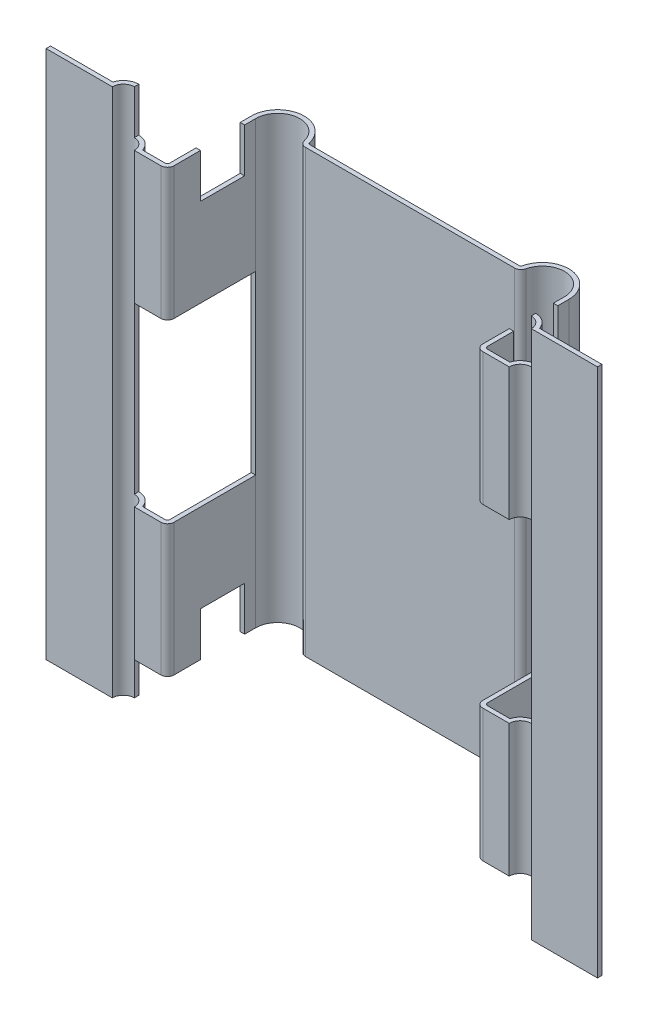
from build123d import *

# Parameters (mm, degrees)
EXTRUDE_THIN1_DEPTH      = 6
EXTRUDE_THIN1_DEPTH_BACK = 6
SKETCH2_W                = 2
SKETCH2_H                = 4
SKETCH2_W_2              = 3
SKETCH2_H_2              = 1
EXTRUDE1_DEPTH           = 4.5
EXTRUDE1_DEPTH_BACK      = 4.5
SKETCH3_W                = 1
SKETCH3_H                = 1
EXTRUDE2_DEPTH           = 10
EXTRUDE2_DEPTH_BACK      = 10


with BuildPart() as part:
    # Sketch1 → Extrude-Thin1 (new body, two sides)
    with BuildSketch(Plane(origin=(0, 0, 0), x_dir=(1, 0, 0), z_dir=(0, 1, 0))) as extrude_thin1_sk:
        with BuildLine():
            Line((-6.25, 0), (-4.75, 0))
            ThreePointArc((-4.75, 0), (-4.5, 0.25), (-4.25, 0))
            Line((-4.25, 0), (-3.65, 0))
            ThreePointArc((-3.65, 0), (-3.543933983, 0.043933983), (-3.5, 0.15))
            Line((-3.5, 0.15), (-3.5, 2.001234471))
            ThreePointArc((-3.5, 2.001234471), (-3.058085593, 2.497849074), (-2.513495745, 2.116619086))
            ThreePointArc((-2.513495745, 2.116619086), (-2.460570519, 2.03356479), (-2.367544468, 2.001234471))
            Line((-2.367544468, 2.001234471), (2.367544468, 2.001234471))
            ThreePointArc((2.367544468, 2.001234471), (2.460570519, 2.03356479), (2.513495745, 2.116619086))
            ThreePointArc((2.513495745, 2.116619086), (3.058085593, 2.497849074), (3.5, 2.001234471))
            Line((3.5, 2.001234471), (3.5, 0.15))
            ThreePointArc((3.5, 0.15), (3.543933983, 0.043933983), (3.65, 0))
            Line((3.65, 0), (4.25, 0))
            ThreePointArc((4.25, 0), (4.5, 0.25), (4.75, 0))
            Line((4.75, 0), (6.25, 0))
            Line((6.25, 0), (6.25, 0.1))
            Line((6.25, 0.1), (4.835410197, 0.1))
            ThreePointArc((4.835410197, 0.1), (4.5, 0.35), (4.164589803, 0.1))
            Line((4.164589803, 0.1), (3.65, 0.1))
            ThreePointArc((3.65, 0.1), (3.614644661, 0.114644661), (3.6, 0.15))
            Line((3.6, 0.15), (3.6, 2.001234471))
            ThreePointArc((3.6, 2.001234471), (3.069702712, 2.597171994), (2.416194894, 2.139696009))
            ThreePointArc((2.416194894, 2.139696009), (2.398553152, 2.112011244), (2.367544468, 2.101234471))
            Line((2.367544468, 2.101234471), (-2.367544468, 2.101234471))
            ThreePointArc((-2.367544468, 2.101234471), (-2.398553152, 2.112011244), (-2.416194894, 2.139696009))
            ThreePointArc((-2.416194894, 2.139696009), (-3.069702712, 2.597171994), (-3.6, 2.001234471))
            Line((-3.6, 2.001234471), (-3.6, 0.15))
            ThreePointArc((-3.6, 0.15), (-3.614644661, 0.114644661), (-3.65, 0.1))
            Line((-3.65, 0.1), (-4.164589803, 0.1))
            ThreePointArc((-4.164589803, 0.1), (-4.5, 0.35), (-4.835410197, 0.1))
            Line((-4.835410197, 0.1), (-6.25, 0.1))
            Line((-6.25, 0.1), (-6.25, 0))
        make_face()
    extrude(amount=EXTRUDE_THIN1_DEPTH)
    extrude(extrude_thin1_sk.sketch, amount=-EXTRUDE_THIN1_DEPTH_BACK)

    # Sketch2 → Extrude1 (cut, two sides)
    with BuildSketch(Plane(origin=(0, 0, 0), x_dir=(0, 0, -1), z_dir=(1, 0, 0))) as extrude1_sk:
        with Locations((1, 0)):
            Rectangle(SKETCH2_W, SKETCH2_H)
        with Locations((1.5, -5.5)):
            Rectangle(SKETCH2_W_2, SKETCH2_H_2)
        with Locations((1.5, 5.5)):
            Rectangle(SKETCH2_W_2, SKETCH2_H_2)
    extrude(amount=EXTRUDE1_DEPTH, mode=Mode.SUBTRACT)
    extrude(extrude1_sk.sketch, amount=-EXTRUDE1_DEPTH_BACK, mode=Mode.SUBTRACT)

    # Sketch3 → Extrude2 (cut, two sides)
    with BuildSketch(Plane(origin=(0, 0, 0), x_dir=(0, 0, -1), z_dir=(1, 0, 0))) as extrude2_sk:
        with Locations((1.25, 4.5)):
            Rectangle(SKETCH3_W, SKETCH3_H)
        with Locations((1.25, -4.5)):
            Rectangle(SKETCH3_W, SKETCH3_H)
    extrude(amount=EXTRUDE2_DEPTH, mode=Mode.SUBTRACT)
    extrude(extrude2_sk.sketch, amount=-EXTRUDE2_DEPTH_BACK, mode=Mode.SUBTRACT)


solid = part.part
